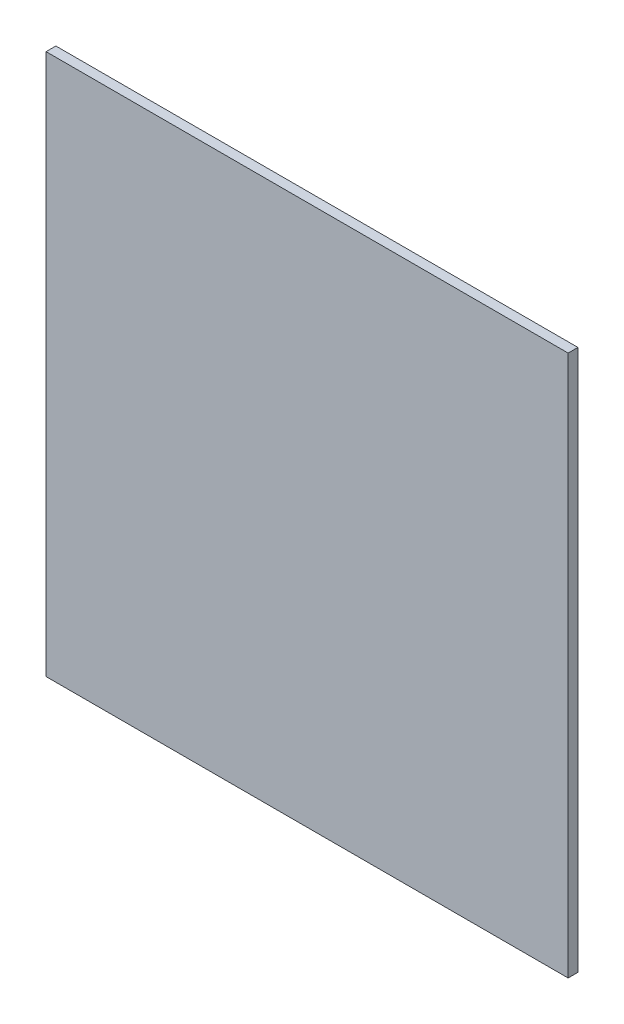
from build123d import *

# Parameters (mm, degrees)
BOSS_EXTRUDE1_DEPTH = 1.5


with BuildPart() as part:
    # Sketch1 → Boss-Extrude1 (new body)
    with BuildSketch(Plane.XY):
        Polygon((-30, -41.469286433), (-40, -41.469286433), (-40, -31.101964825), (-40, 41.469286433), (40, 41.469286433), (40, -41.469286433), align=None)
    extrude(amount=BOSS_EXTRUDE1_DEPTH)


solid = part.part
